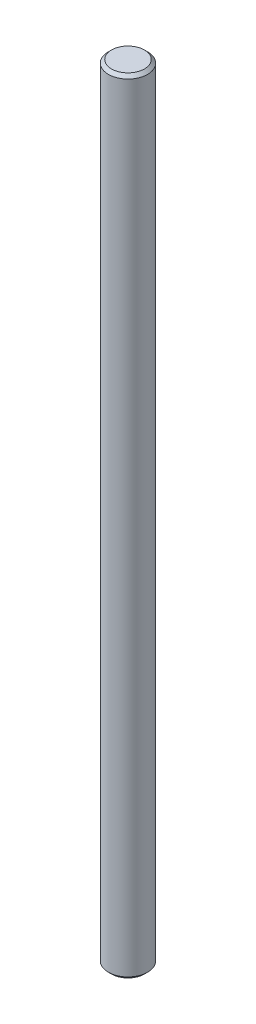
from build123d import *

# Parameters (mm, degrees)
SKETCH1_R      = 2.5
EXTRUDE1_DEPTH = 100
CHAMFER1_SIZE  = 0.4


with BuildPart() as part:
    # Sketch1 → Extrude1 (new body)
    with BuildSketch(Plane(origin=(0, 0, 0), x_dir=(1, 0, 0), z_dir=(0, 1, 0))):
        with Locations(Location((0, 0, 0), (0, 0, 270))):  # turned: the seam where the file's is
            Circle(SKETCH1_R)
    extrude(amount=EXTRUDE1_DEPTH)

    # Chamfer1
    chamfer1_edges = [part.edges().sort_by_distance(p)[0] for p in [
        (0, 0, -2.5),
        (0, 100, -2.5),
    ]]
    chamfer(chamfer1_edges, length=CHAMFER1_SIZE)


solid = part.part
